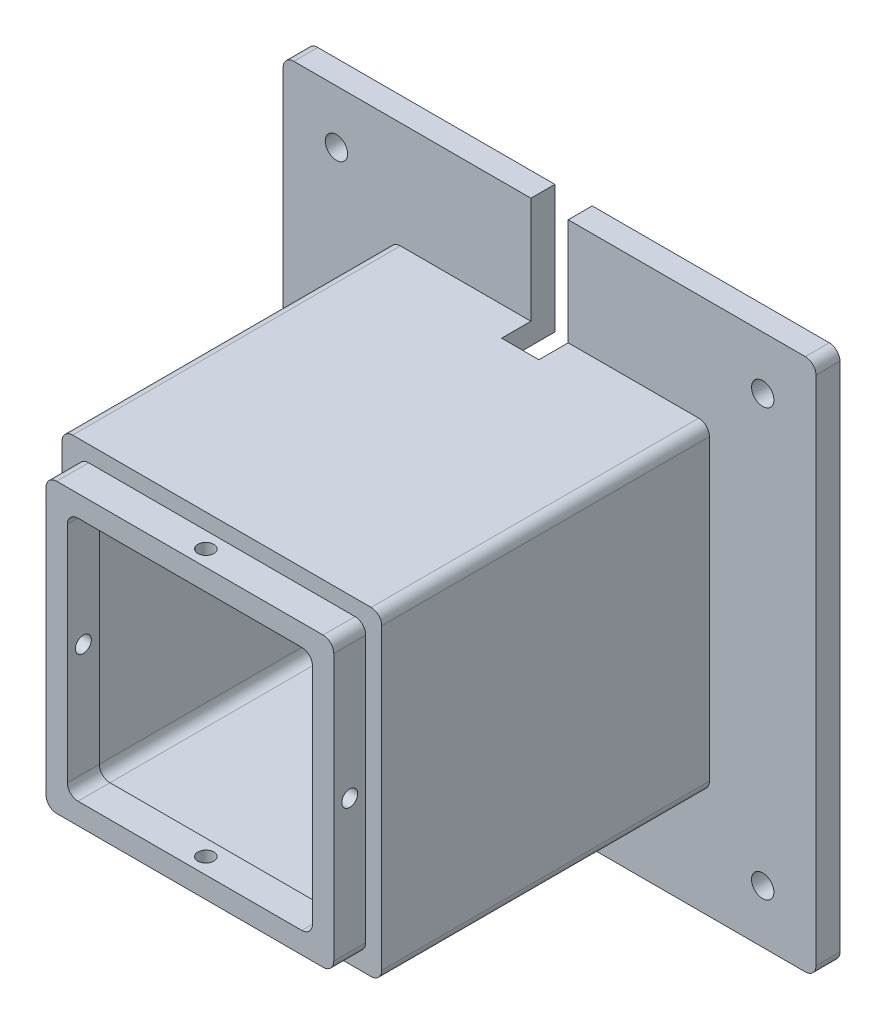
from build123d import *

# Parameters (mm, degrees)
SKETCH_1_W                = 60
SKETCH_1_H                = 60
EXTRUDE_1_DEPTH           = 55.5
SKETCH_2_W                = 50
SKETCH_2_H                = 50
CUT_EXTRUDE_3_DEPTH       = 49.5
SKETCH_4_W                = 38.4
SKETCH_4_H                = 38.4
CUT_EXTRUDE_4_DEPTH       = 4
SKETCH_5_W                = 8
SKETCH_5_H                = 8
EXTRUDE_3_DEPTH           = 2.5
CUT_EXTRUDE_5_REACH       = 56
SKETCH_6_R                = 1.25
SKETCH_7_R                = 11.5
CUT_EXTRUDE_6_DEPTH       = 2.5
FILLET_5_R                = 1
SKETCH_12_W               = 60
SKETCH_12_H               = 60
CUT_EXTRUDE_9_DEPTH       = 3
SKETCH_17_W               = 60
SKETCH_17_H               = 60
EXTRUDE_5_DEPTH           = 13.5
SKETCH_20_W               = 54
SKETCH_20_H               = 54
EXTRUDE_6_DEPTH           = 6
SKETCH_21_W               = 46
SKETCH_21_H               = 46
CUT_EXTRUDE_18_DEPTH      = 6
FILLET_9_R                = 2
FILLET_10_R               = 2
SKETCH_24_W               = 52
SKETCH_24_H               = 52
CUT_EXTRUDE_21_DEPTH      = 13.5
CUT_EXTRUDE_22_REACH      = 62
SKETCH_25_W               = 7
SKETCH_25_H               = 20
EXTRUDE_7_DEPTH           = 4.5
SKETCH_27_W               = 52
SKETCH_27_H               = 52
CUT_EXTRUDE_24_DEPTH      = 4.5
SKETCH_28_W               = 7
SKETCH_28_H               = 24
CUT_EXTRUDE_25_DEPTH      = 4.5
CUT_EXTRUDE_26_REACH      = 74
SKETCH_29_R               = 2.1
FILLET_12_R               = 2
SKETCH_30_R               = 1.5
CUT_EXTRUDE_27_DEPTH      = 24
CUT_EXTRUDE_27_DEPTH_BACK = 78
SKETCH_31_R               = 1.5
CUT_EXTRUDE_28_DEPTH      = 24
CUT_EXTRUDE_28_DEPTH_BACK = 78
FILLET_13_R               = 2
FILLET_14_R               = 2


with BuildPart() as part:
    # 草图1 → 凸台-拉伸1 (new body)
    with BuildSketch(Plane.XY):
        Rectangle(SKETCH_1_W, SKETCH_1_H)
    extrude(amount=EXTRUDE_1_DEPTH)

    # 草图2 → 切除-拉伸3 (cut)
    with BuildSketch(Plane.XY.offset(55.5)):
        Rectangle(SKETCH_2_W, SKETCH_2_H)
    extrude(amount=-CUT_EXTRUDE_3_DEPTH, mode=Mode.SUBTRACT)

    # 草图4 → 切除-拉伸4 (cut)
    with BuildSketch(Plane(origin=(0, 0, 0), x_dir=(-1, 0, 0), z_dir=(0, 0, -1))):
        Rectangle(SKETCH_4_W, SKETCH_4_H)
    extrude(amount=-CUT_EXTRUDE_4_DEPTH, mode=Mode.SUBTRACT)

    # 草图5 → 凸台-拉伸3 (add)
    with BuildSketch(Plane(origin=(0, 0, 4), x_dir=(-1, 0, 0), z_dir=(0, 0, -1))):
        with Locations((-15.2, 15.2)):
            Rectangle(SKETCH_5_W, SKETCH_5_H)
        with Locations((15.2, 15.2)):
            Rectangle(SKETCH_5_W, SKETCH_5_H)
        with Locations((15.2, -15.2)):
            Rectangle(SKETCH_5_W, SKETCH_5_H)
        with Locations((-15.2, -15.2)):
            Rectangle(SKETCH_5_W, SKETCH_5_H)
    extrude(amount=EXTRUDE_3_DEPTH)

    # 草图6 → 切除-拉伸5 (cut, up to next)
    with BuildSketch(Plane(origin=(0, 0, 1.5), x_dir=(-1, 0, 0), z_dir=(0, 0, -1)), mode=Mode.PRIVATE) as cut_extrude_5_sk1:
        with Locations((-14, 14)):
            Circle(SKETCH_6_R)
    cut_extrude_5_tool1 = extrude(cut_extrude_5_sk1.sketch, amount=-CUT_EXTRUDE_5_REACH, mode=Mode.PRIVATE) & part.part
    add(cut_extrude_5_tool1.solids().sort_by_distance((14, 14, 1.5))[0], mode=Mode.SUBTRACT)
    # 草图6 → 切除-拉伸5 (cut, up to next)
    with BuildSketch(Plane(origin=(0, 0, 1.5), x_dir=(-1, 0, 0), z_dir=(0, 0, -1)), mode=Mode.PRIVATE) as cut_extrude_5_sk2:
        with Locations((14, 14)):
            Circle(SKETCH_6_R)
    cut_extrude_5_tool2 = extrude(cut_extrude_5_sk2.sketch, amount=-CUT_EXTRUDE_5_REACH, mode=Mode.PRIVATE) & part.part
    add(cut_extrude_5_tool2.solids().sort_by_distance((-14, 14, 1.5))[0], mode=Mode.SUBTRACT)
    # 草图6 → 切除-拉伸5 (cut, up to next)
    with BuildSketch(Plane(origin=(0, 0, 1.5), x_dir=(-1, 0, 0), z_dir=(0, 0, -1)), mode=Mode.PRIVATE) as cut_extrude_5_sk3:
        with Locations((-14, -14)):
            Circle(SKETCH_6_R)
    cut_extrude_5_tool3 = extrude(cut_extrude_5_sk3.sketch, amount=-CUT_EXTRUDE_5_REACH, mode=Mode.PRIVATE) & part.part
    add(cut_extrude_5_tool3.solids().sort_by_distance((14, -14, 1.5))[0], mode=Mode.SUBTRACT)
    # 草图6 → 切除-拉伸5 (cut, up to next)
    with BuildSketch(Plane(origin=(0, 0, 1.5), x_dir=(-1, 0, 0), z_dir=(0, 0, -1)), mode=Mode.PRIVATE) as cut_extrude_5_sk4:
        with Locations((13.997534232, -14.034417217)):
            Circle(SKETCH_6_R)
    cut_extrude_5_tool4 = extrude(cut_extrude_5_sk4.sketch, amount=-CUT_EXTRUDE_5_REACH, mode=Mode.PRIVATE) & part.part
    add(cut_extrude_5_tool4.solids().sort_by_distance((-13.997534, -14.034417, 1.5))[0], mode=Mode.SUBTRACT)

    # 草图7 → 切除-拉伸6 (cut)
    with BuildSketch(Plane(origin=(0, 0, 4), x_dir=(-1, 0, 0), z_dir=(0, 0, -1))):
        Circle(SKETCH_7_R)
    extrude(amount=-CUT_EXTRUDE_6_DEPTH, mode=Mode.SUBTRACT)

    # 圆角5
    fillet_5_edges = [part.edges().sort_by_distance(p)[0] for p in [
        (19.2, 11.2, 2.75),
        (11.2, 11.2, 2.75),
        (11.2, 19.2, 2.75),
        (-19.2, 11.2, 2.75),
        (-11.2, 19.2, 2.75),
        (-11.2, 11.2, 2.75),
        (-19.2, -11.2, 2.75),
        (-11.2, -11.2, 2.75),
        (-11.2, -19.2, 2.75),
        (19.2, -11.2, 2.75),
        (11.2, -19.2, 2.75),
        (11.2, -11.2, 2.75),
    ]]
    fillet(fillet_5_edges, radius=FILLET_5_R)

    # 草图12 → 切除-拉伸9 (cut)
    with BuildSketch(Plane.XY.offset(55.5)):
        Rectangle(SKETCH_12_W, SKETCH_12_H)
    extrude(amount=-CUT_EXTRUDE_9_DEPTH, mode=Mode.SUBTRACT)

    # 草图17 → 凸台-拉伸5 (add)
    with BuildSketch(Plane(origin=(0, 0, 0), x_dir=(-1, 0, 0), z_dir=(0, 0, -1))):
        Rectangle(SKETCH_17_W, SKETCH_17_H)
    extrude(amount=EXTRUDE_5_DEPTH)

    # 草图20 → 凸台-拉伸6 (add)
    with BuildSketch(Plane.XY.offset(52.5)):
        Rectangle(SKETCH_20_W, SKETCH_20_H)
    extrude(amount=EXTRUDE_6_DEPTH)

    # 草图21 → 切除-拉伸18 (cut)
    with BuildSketch(Plane.XY.offset(58.5)):
        Rectangle(SKETCH_21_W, SKETCH_21_H)
    extrude(amount=-CUT_EXTRUDE_18_DEPTH, mode=Mode.SUBTRACT)

    # 圆角9
    fillet_9_edges = [part.edges().sort_by_distance(p)[0] for p in [
        (25, 25, 29.25),
        (25, -25, 29.25),
        (-25, -25, 29.25),
        (-25, 25, 29.25),
        (23, 23, 55.5),
        (23, -23, 55.5),
        (-23, -23, 55.5),
        (-23, 23, 55.5),
    ]]
    fillet(fillet_9_edges, radius=FILLET_9_R)

    # 圆角10
    fillet_10_edges = [part.edges().sort_by_distance(p)[0] for p in [
        (-27, -27, 55.5),
        (27, -27, 55.5),
        (27, 27, 55.5),
        (-27, 27, 55.5),
    ]]
    fillet(fillet_10_edges, radius=FILLET_10_R)

    # 草图24 → 切除-拉伸21 (cut)
    with BuildSketch(Plane(origin=(0, 0, -13.5), x_dir=(-1, 0, 0), z_dir=(0, 0, -1))):
        Rectangle(SKETCH_24_W, SKETCH_24_H)
    extrude(amount=-CUT_EXTRUDE_21_DEPTH, mode=Mode.SUBTRACT)

    # 草图25 → 切除-拉伸22 (cut, up to next)
    with BuildSketch(Plane(origin=(0, 30, 0), x_dir=(1, 0, 0), z_dir=(0, 1, 0)), mode=Mode.PRIVATE) as cut_extrude_22_sk1:
        with Locations((0, 13.5)):
            Rectangle(SKETCH_25_W, SKETCH_25_H)
    cut_extrude_22_tool1 = extrude(cut_extrude_22_sk1.sketch, amount=-CUT_EXTRUDE_22_REACH, mode=Mode.PRIVATE) & part.part
    add(cut_extrude_22_tool1.solids().sort_by_distance((0, 30, -13.5))[0], mode=Mode.SUBTRACT)

    # 草图26 → 凸台-拉伸7 (add)
    with BuildSketch(Plane(origin=(0, 0, -13.5), x_dir=(-1, 0, 0), z_dir=(0, 0, -1))):
        Polygon((-31.5, -50), (-50, -50), (-50, 31.5), (-50, 50), (30, 50), (50, 50), (50, -31.5), (50, -50), align=None)
    extrude(amount=-EXTRUDE_7_DEPTH)

    # 草图27 → 切除-拉伸24 (cut)
    with BuildSketch(Plane(origin=(0, 0, -13.5), x_dir=(-1, 0, 0), z_dir=(0, 0, -1))):
        Rectangle(SKETCH_27_W, SKETCH_27_H)
    extrude(amount=-CUT_EXTRUDE_24_DEPTH, mode=Mode.SUBTRACT)

    # 草图28 → 切除-拉伸25 (cut)
    with BuildSketch(Plane(origin=(0, 0, -13.5), x_dir=(-1, 0, 0), z_dir=(0, 0, -1))):
        with Locations((0, 38)):
            Rectangle(SKETCH_28_W, SKETCH_28_H)
    extrude(amount=-CUT_EXTRUDE_25_DEPTH, mode=Mode.SUBTRACT)

    # 草图29 → 切除-拉伸26 (cut, up to next)
    with BuildSketch(Plane(origin=(0, 0, -13.5), x_dir=(-1, 0, 0), z_dir=(0, 0, -1)), mode=Mode.PRIVATE) as cut_extrude_26_sk1:
        with Locations((-40, 40)):
            Circle(SKETCH_29_R)
    cut_extrude_26_tool1 = extrude(cut_extrude_26_sk1.sketch, amount=-CUT_EXTRUDE_26_REACH, mode=Mode.PRIVATE) & part.part
    add(cut_extrude_26_tool1.solids().sort_by_distance((40, 40, -13.5))[0], mode=Mode.SUBTRACT)
    # 草图29 → 切除-拉伸26 (cut, up to next)
    with BuildSketch(Plane(origin=(0, 0, -13.5), x_dir=(-1, 0, 0), z_dir=(0, 0, -1)), mode=Mode.PRIVATE) as cut_extrude_26_sk2:
        with Locations((40, 40)):
            Circle(SKETCH_29_R)
    cut_extrude_26_tool2 = extrude(cut_extrude_26_sk2.sketch, amount=-CUT_EXTRUDE_26_REACH, mode=Mode.PRIVATE) & part.part
    add(cut_extrude_26_tool2.solids().sort_by_distance((-40, 40, -13.5))[0], mode=Mode.SUBTRACT)
    # 草图29 → 切除-拉伸26 (cut, up to next)
    with BuildSketch(Plane(origin=(0, 0, -13.5), x_dir=(-1, 0, 0), z_dir=(0, 0, -1)), mode=Mode.PRIVATE) as cut_extrude_26_sk3:
        with Locations((40, -40)):
            Circle(SKETCH_29_R)
    cut_extrude_26_tool3 = extrude(cut_extrude_26_sk3.sketch, amount=-CUT_EXTRUDE_26_REACH, mode=Mode.PRIVATE) & part.part
    add(cut_extrude_26_tool3.solids().sort_by_distance((-40, -40, -13.5))[0], mode=Mode.SUBTRACT)
    # 草图29 → 切除-拉伸26 (cut, up to next)
    with BuildSketch(Plane(origin=(0, 0, -13.5), x_dir=(-1, 0, 0), z_dir=(0, 0, -1)), mode=Mode.PRIVATE) as cut_extrude_26_sk4:
        with Locations((-40, -40)):
            Circle(SKETCH_29_R)
    cut_extrude_26_tool4 = extrude(cut_extrude_26_sk4.sketch, amount=-CUT_EXTRUDE_26_REACH, mode=Mode.PRIVATE) & part.part
    add(cut_extrude_26_tool4.solids().sort_by_distance((40, -40, -13.5))[0], mode=Mode.SUBTRACT)

    # 圆角12
    fillet_12_edges = [part.edges().sort_by_distance(p)[0] for p in [
        (-30, -30, 21.75),
        (-30, 30, 21.75),
        (30, 30, 21.75),
        (30, -30, 21.75),
    ]]
    fillet(fillet_12_edges, radius=FILLET_12_R)

    # 草图30 → 切除-拉伸27 (cut, two sides)
    with BuildSketch(Plane.ZY.offset(27)) as cut_extrude_27_sk:
        with Locations((55.5, 0)):
            Circle(SKETCH_30_R)
    extrude(amount=CUT_EXTRUDE_27_DEPTH, mode=Mode.SUBTRACT)
    extrude(cut_extrude_27_sk.sketch, amount=-CUT_EXTRUDE_27_DEPTH_BACK, mode=Mode.SUBTRACT)

    # 草图31 → 切除-拉伸28 (cut, two sides)
    with BuildSketch(Plane(origin=(0, 27, 0), x_dir=(1, 0, 0), z_dir=(0, 1, 0))) as cut_extrude_28_sk:
        with Locations((0, -55.5)):
            Circle(SKETCH_31_R)
    extrude(amount=CUT_EXTRUDE_28_DEPTH, mode=Mode.SUBTRACT)
    extrude(cut_extrude_28_sk.sketch, amount=-CUT_EXTRUDE_28_DEPTH_BACK, mode=Mode.SUBTRACT)

    # 圆角13
    fillet_13_edges = [part.edges().sort_by_distance(p)[0] for p in [
        (-26, 26, -6.75),
        (-26, -26, -6.75),
        (26, -26, -6.75),
        (26, 26, -6.75),
    ]]
    fillet(fillet_13_edges, radius=FILLET_13_R)

    # 圆角14
    fillet_14_edges = [part.edges().sort_by_distance(p)[0] for p in [
        (50, -50, -11.25),
        (50, 50, -11.25),
        (-50, 50, -11.25),
        (-50, -50, -11.25),
    ]]
    fillet(fillet_14_edges, radius=FILLET_14_R)


solid = part.part
